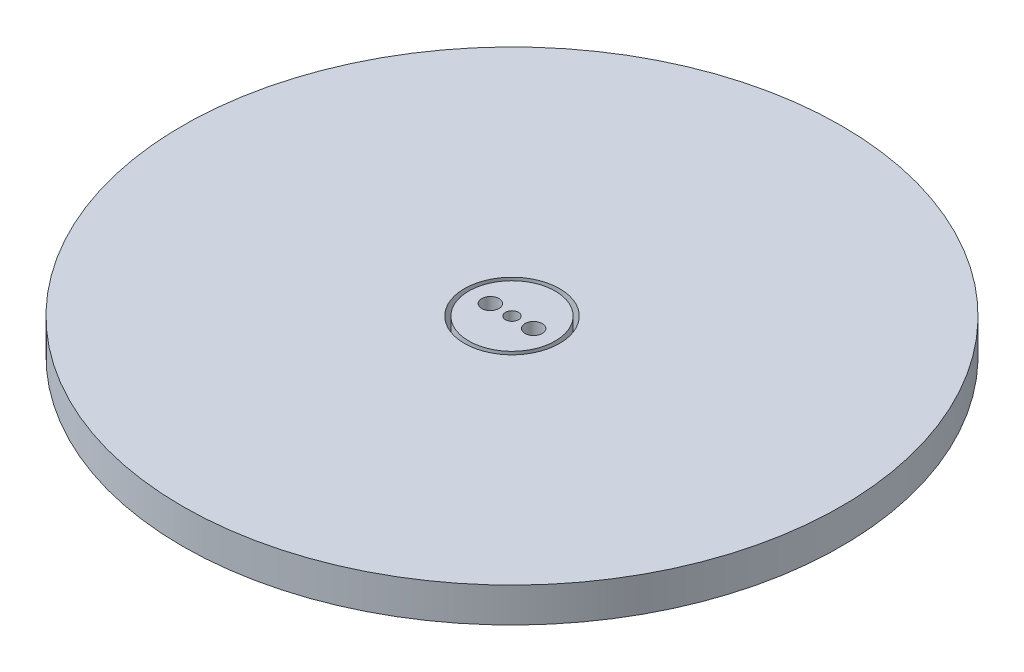
from build123d import *

# Parameters (mm, degrees)
SKETCH1_R           = 5
SKETCH1_R_2         = 0.75
SKETCH1_R_3         = 1
BOSS_EXTRUDE1_DEPTH = 2
SKETCH2_R           = 38.1
SKETCH2_R_2         = 5.5
BOSS_EXTRUDE2_DEPTH = 4


with BuildPart() as part:
    # Sketch1 → Boss-Extrude1 (new body, symmetric)
    with BuildSketch(Plane(origin=(0, 0, 0), x_dir=(1, 0, 0), z_dir=(0, 1, 0))):
        Circle(SKETCH1_R)
        Circle(SKETCH1_R_2, mode=Mode.SUBTRACT)
        with Locations((-2.5, 0)):
            Circle(SKETCH1_R_3, mode=Mode.SUBTRACT)
        with Locations((2.5, 0)):
            Circle(SKETCH1_R_3, mode=Mode.SUBTRACT)
    extrude(amount=BOSS_EXTRUDE1_DEPTH, both=True)


with BuildPart() as body_2:
    # Sketch2 → Boss-Extrude2 (new body)
    with BuildSketch(Plane.XZ.offset(2)):
        Circle(SKETCH2_R)
        Circle(SKETCH2_R_2, mode=Mode.SUBTRACT)
    extrude(amount=-BOSS_EXTRUDE2_DEPTH)


solid = Compound([part.part, body_2.part])
